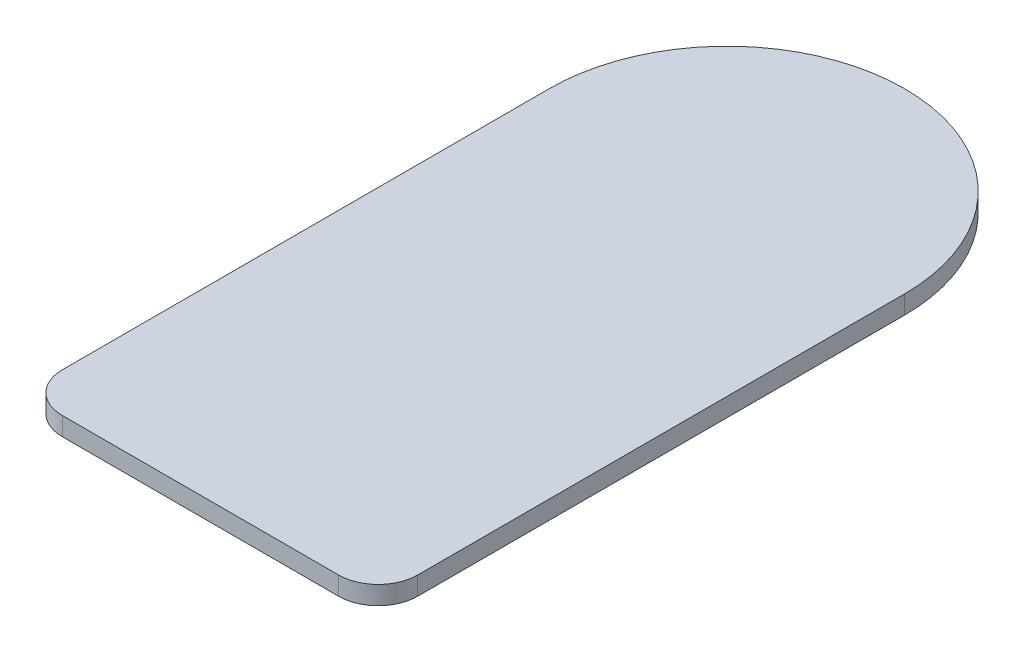
from build123d import *

# Parameters (mm, degrees)
BOSS_EXTRUDE1_DEPTH = 7


with BuildPart() as part:
    # Sketch1 → Boss-Extrude1 (new body)
    with BuildSketch(Plane(origin=(0, 0, 0), x_dir=(1, 0, 0), z_dir=(0, 1, 0))):
        with BuildLine():
            Line((52.5, -100), (-52.5, -100))
            ThreePointArc((-52.5, -100), (-63.106601718, -95.606601718), (-67.5, -85))
            Line((-67.5, -85), (-67.5, 100))
            ThreePointArc((-67.5, 100), (0, 167.5), (67.5, 100))
            Line((67.5, 100), (67.5, -85))
            ThreePointArc((67.5, -85), (63.106601718, -95.606601718), (52.5, -100))
        make_face()
    extrude(amount=BOSS_EXTRUDE1_DEPTH)


solid = part.part
